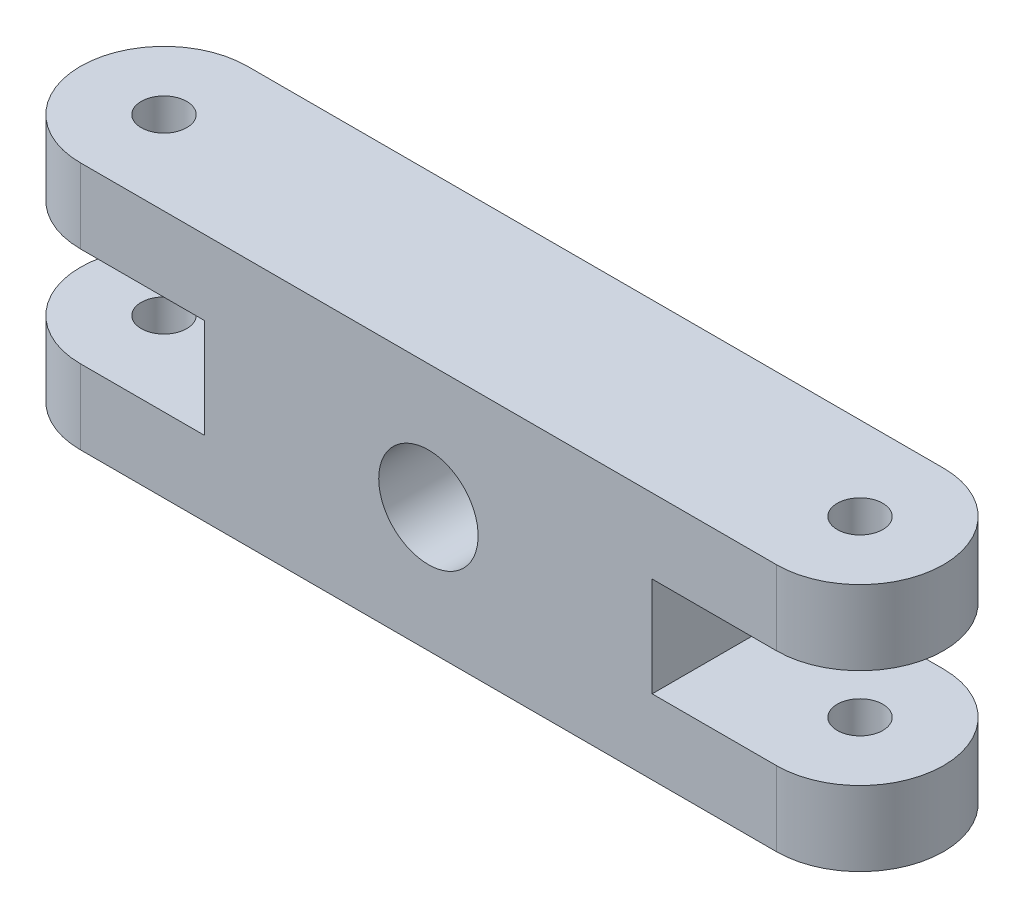
from build123d import *

# Parameters (mm, degrees)
SKETCH1_R           = 2.75
BOSS_EXTRUDE1_DEPTH = 30
SKETCH4_W           = 40.854954683
SKETCH4_H           = 12
CUT_EXTRUDE1_DEPTH  = 27
CUT_EXTRUDE2_DEPTH  = 27


with BuildPart() as part:
    # Sketch1 → Boss-Extrude1 (new body)
    with BuildSketch(Plane(origin=(0, 0, 0), x_dir=(1, 0, 0), z_dir=(0, 1, 0))):
        with BuildLine():
            Line((42, 10.085339835), (-42, 10.085339835))
            ThreePointArc((-42, 10.085339835), (-52.085339835, 0), (-42, -10.085339835))
            Line((-42, -10.085339835), (42, -10.085339835))
            ThreePointArc((42, -10.085339835), (52.085339835, 0), (42, 10.085339835))
        make_face()
        with Locations((-42, 0)):
            Circle(SKETCH1_R, mode=Mode.SUBTRACT)
        with Locations((42, 0)):
            Circle(SKETCH1_R, mode=Mode.SUBTRACT)
    extrude(amount=BOSS_EXTRUDE1_DEPTH)

    # Sketch4 → Cut-Extrude1 (cut)
    with BuildSketch(Plane(origin=(0, 0, -10.085339835), x_dir=(-1, 0, 0), z_dir=(0, 0, -1))):
        with Locations((47.427477342, 15)):
            Rectangle(SKETCH4_W, SKETCH4_H)
        with Locations((-47.427477342, 15)):
            Rectangle(SKETCH4_W, SKETCH4_H)
    extrude(amount=-CUT_EXTRUDE1_DEPTH, mode=Mode.SUBTRACT)

    # Sketch4_3 → Cut-Extrude2 (cut)
    with BuildSketch(Plane(origin=(0, 0, -10.085339835), x_dir=(-1, 0, 0), z_dir=(0, 0, -1))):
        with BuildLine():
            ThreePointArc((0, 9), (4.242640687, 10.757359313), (6, 15))
            ThreePointArc((6, 15), (-4.242640687, 19.242640687), (0, 9))
        make_face()
    extrude(amount=-CUT_EXTRUDE2_DEPTH, mode=Mode.SUBTRACT)


solid = part.part
